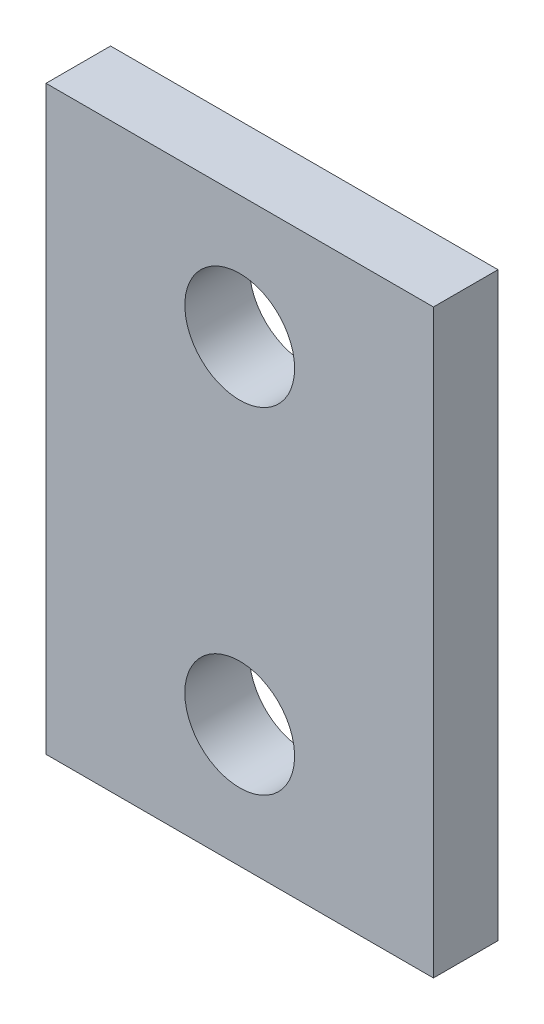
from build123d import *

# Parameters (mm, degrees)
SKETCH1_W           = 30
SKETCH1_H           = 45
SKETCH1_R           = 4.25
BOSS_EXTRUDE1_DEPTH = 5


with BuildPart() as part:
    # Sketch1 → Boss-Extrude1 (new body)
    with BuildSketch(Plane.XY):
        Rectangle(SKETCH1_W, SKETCH1_H)
        with Locations((0, 13)):
            Circle(SKETCH1_R, mode=Mode.SUBTRACT)
        with Locations((0, -13)):
            Circle(SKETCH1_R, mode=Mode.SUBTRACT)
    extrude(amount=BOSS_EXTRUDE1_DEPTH)


solid = part.part
